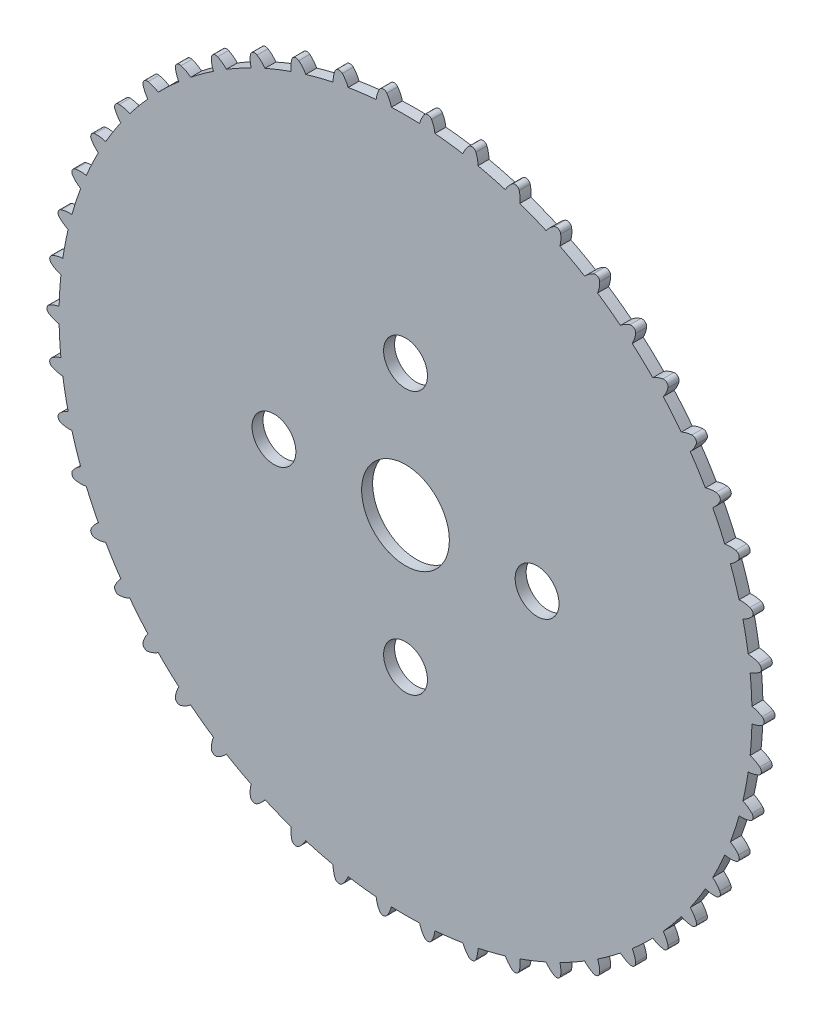
from build123d import *

# Parameters (mm, degrees)
SKETCH1_R           = 4
BOSS_EXTRUDE1_DEPTH = 1
FILLET1_R           = 0.4
FILLET2_R           = 0.4
FILLET3_R           = 0.4
SKETCH2_R           = 2
CUT_EXTRUDE1_DEPTH  = 1


with BuildPart() as part:
    # Sketch1 → Boss-Extrude1 (new body)
    with BuildSketch(Plane.XY):
        with BuildLine():
            ThreePointArc((-31.605983116, -0.694944521), (-31.599169752, -0.69498613), (-31.592356275, -0.695))
            ThreePointArc((-31.592356275, -0.695), (-31.592329775, -0.696203545), (-31.59230323, -0.697407089))
            ThreePointArc((-31.59230323, -0.697407089), (-31.537644618, -1.984180417), (-31.430596768, -3.267657694))
            ThreePointArc((-31.430596768, -3.267657694), (-32.125334488, -3.603800027), (-32.690179408, -4.129730046))
            ThreePointArc((-32.690179408, -4.129730046), (-32.012286653, -4.498665787), (-31.255780197, -4.651473345))
            ThreePointArc((-31.255780197, -4.651473345), (-31.040277123, -5.921249541), (-30.77321102, -7.181189563))
            ThreePointArc((-30.77321102, -7.181189563), (-31.42034072, -7.601755038), (-31.914815159, -8.194331782))
            ThreePointArc((-31.914815159, -8.194331782), (-31.196027882, -8.475395863), (-30.426334839, -8.532183088))
            ThreePointArc((-30.426334839, -8.532183088), (-30.053385915, -9.764937022), (-29.630513351, -10.981469782))
            ThreePointArc((-29.630513351, -10.981469782), (-30.219829409, -11.479825831), (-30.63613521, -12.129704011))
            ThreePointArc((-30.63613521, -12.129704011), (-29.887789115, -12.318463884), (-29.117048005, -12.278335207))
            ThreePointArc((-29.117048005, -12.278335207), (-28.592534858, -13.454625613), (-28.020524786, -14.608565663))
            ThreePointArc((-28.020524786, -14.608565663), (-28.542733336, -15.176852913), (-28.874305107, -15.873783562))
            ThreePointArc((-28.874305107, -15.873783562), (-28.108202059, -15.967262371), (-27.348567931, -15.830850645))
            ThreePointArc((-27.348567931, -15.830850645), (-26.680762446, -16.932126721), (-25.968635806, -18.005275737))
            ThreePointArc((-25.968635806, -18.005275737), (-26.415501307, -18.634531959), (-26.657109965, -19.367524063))
            ThreePointArc((-26.657109965, -19.367524063), (-25.885331866, -19.364247592), (-25.148784602, -19.133704111))
            ThreePointArc((-25.148784602, -19.133704111), (-24.348218472, -20.142598076), (-23.507205927, -21.118031857))
            ThreePointArc((-23.507205927, -21.118031857), (-23.871681043, -21.798333304), (-24.019516274, -22.55582714))
            ThreePointArc((-24.019516274, -22.55582714), (-23.254234527, -22.45584706), (-22.552389918, -22.134807634))
            ThreePointArc((-22.552389918, -22.134807634), (-21.631688547, -23.035408627), (-20.675053368, -23.897743999))
            ThreePointArc((-20.675053368, -23.897743999), (-20.951390109, -24.61836191), (-21.003120462, -25.388411349))
            ThreePointArc((-21.003120462, -25.388411349), (-20.256404017, -25.193304406), (-19.600330572, -24.786832017))
            ThreePointArc((-19.600330572, -24.786832017), (-18.574013972, -25.564937022), (-17.516842866, -26.300574442))
            ThreePointArc((-17.516842866, -26.300574442), (-17.700683236, -27.050144243), (-17.655492895, -27.820605145))
            ThreePointArc((-17.655492895, -27.820605145), (-16.939117916, -27.533448292), (-16.339162305, -27.047953253))
            ThreePointArc((-16.339162305, -27.047953253), (-15.223416102, -27.691291089), (-14.082381289, -28.288629116))
            ThreePointArc((-14.082381289, -28.288629116), (-14.170826016, -29.055329643), (-14.029427657, -29.814051379))
            ThreePointArc((-14.029427657, -29.814051379), (-13.354691806, -29.439373251), (-12.820315687, -28.882512108))
            ThreePointArc((-12.820315687, -28.882512108), (-11.632735865, -29.380936954), (-10.425832146, -29.830555209))
            ThreePointArc((-10.425832146, -29.830555209), (-10.417486404, -30.602295137), (-10.182109965, -31.337312212))
            ThreePointArc((-10.182109965, -31.337312212), (-9.559654229, -30.881021707), (-9.099285033, -30.261576494))
            ThreePointArc((-9.099285033, -30.261576494), (-7.858600434, -30.607227892), (-6.604861402, -30.902035626))
            ThreePointArc((-6.604861402, -30.902035626), (-6.499856808, -31.666644156), (-6.174214316, -32.366364912))
            ThreePointArc((-6.174214316, -32.366364912), (-5.613855194, -31.835658003), (-5.234753218, -31.163397741))
            ThreePointArc((-5.234753218, -31.163397741), (-3.960530181, -31.350824562), (-2.679728048, -31.486172482))
            ThreePointArc((-2.679728048, -31.486172482), (-2.479720587, -32.23159128), (-2.068947618, -32.884980702))
            ThreePointArc((-2.068947618, -32.884980702), (-1.579522308, -32.288226955), (-1.287666218, -31.573753589))
            ThreePointArc((-1.287666218, -31.573753589), (0, -31.6), (1.287666218, -31.573753589))
            ThreePointArc((1.287666218, -31.573753589), (1.579522308, -32.288226955), (2.068947618, -32.884980702))
            ThreePointArc((2.068947618, -32.884980702), (2.479720587, -32.23159128), (2.679728048, -31.486172482))
            ThreePointArc((2.679728048, -31.486172482), (3.960530181, -31.350824562), (5.234753218, -31.163397741))
            ThreePointArc((5.234753218, -31.163397741), (5.613855194, -31.835658003), (6.174214316, -32.366364912))
            ThreePointArc((6.174214316, -32.366364912), (6.499856808, -31.666644156), (6.604861402, -30.902035626))
            ThreePointArc((6.604861402, -30.902035626), (7.858600434, -30.607227892), (9.099285033, -30.261576494))
            ThreePointArc((9.099285033, -30.261576494), (9.559654229, -30.881021707), (10.182109965, -31.337312212))
            ThreePointArc((10.182109965, -31.337312212), (10.417486404, -30.602295137), (10.425832146, -29.830555209))
            ThreePointArc((10.425832146, -29.830555209), (11.632735865, -29.380936954), (12.820315687, -28.882512108))
            ThreePointArc((12.820315687, -28.882512108), (13.354691806, -29.439373251), (14.029427657, -29.814051379))
            ThreePointArc((14.029427657, -29.814051379), (14.170826016, -29.055329643), (14.082381289, -28.288629116))
            ThreePointArc((14.082381289, -28.288629116), (15.223416102, -27.691291089), (16.339162305, -27.047953253))
            ThreePointArc((16.339162305, -27.047953253), (16.939117916, -27.533448292), (17.655492895, -27.820605145))
            ThreePointArc((17.655492895, -27.820605145), (17.700683236, -27.050144243), (17.516842866, -26.300574442))
            ThreePointArc((17.516842866, -26.300574442), (18.574013972, -25.564937022), (19.600330572, -24.786832017))
            ThreePointArc((19.600330572, -24.786832017), (20.256404017, -25.193304406), (21.003120462, -25.388411349))
            ThreePointArc((21.003120462, -25.388411349), (20.951390109, -24.61836191), (20.675053368, -23.897743999))
            ThreePointArc((20.675053368, -23.897743999), (21.631688547, -23.035408627), (22.552389918, -22.134807634))
            ThreePointArc((22.552389918, -22.134807634), (23.254234527, -22.45584706), (24.019516274, -22.55582714))
            ThreePointArc((24.019516274, -22.55582714), (23.871681043, -21.798333304), (23.507205927, -21.118031857))
            ThreePointArc((23.507205927, -21.118031857), (24.348218472, -20.142598076), (25.148784602, -19.133704111))
            ThreePointArc((25.148784602, -19.133704111), (25.885331866, -19.364247592), (26.657109965, -19.367524063))
            ThreePointArc((26.657109965, -19.367524063), (26.415501307, -18.634531959), (25.968635806, -18.005275737))
            ThreePointArc((25.968635806, -18.005275737), (26.680762446, -16.932126721), (27.348567931, -15.830850645))
            ThreePointArc((27.348567931, -15.830850645), (28.108202059, -15.967262371), (28.874305107, -15.873783562))
            ThreePointArc((28.874305107, -15.873783562), (28.542733336, -15.176852913), (28.020524786, -14.608565663))
            ThreePointArc((28.020524786, -14.608565663), (28.592534858, -13.454625613), (29.117048005, -12.278335207))
            ThreePointArc((29.117048005, -12.278335207), (29.887789115, -12.318463884), (30.63613521, -12.129704011))
            ThreePointArc((30.63613521, -12.129704011), (30.219829409, -11.479825831), (29.630513351, -10.981469782))
            ThreePointArc((29.630513351, -10.981469782), (30.053385915, -9.764937022), (30.426334839, -8.532183088))
            ThreePointArc((30.426334839, -8.532183088), (31.196027882, -8.475395863), (31.914815159, -8.194331782))
            ThreePointArc((31.914815159, -8.194331782), (31.42034072, -7.601755038), (30.77321102, -7.181189563))
            ThreePointArc((30.77321102, -7.181189563), (31.040277123, -5.921249541), (31.255780197, -4.651473345))
            ThreePointArc((31.255780197, -4.651473345), (32.012286653, -4.498665787), (32.690179408, -4.129730046))
            ThreePointArc((32.690179408, -4.129730046), (32.125334488, -3.603800027), (31.430596768, -3.267657694))
            ThreePointArc((31.430596768, -3.267657694), (31.537644618, -1.984180417), (31.59230323, -0.697407089))
            ThreePointArc((31.59230323, -0.697407089), (32.323692541, -0.450989063), (32.95, 0))
            ThreePointArc((32.95, 0), (32.323692541, 0.450989063), (31.59230323, 0.697407089))
            ThreePointArc((31.59230323, 0.697407089), (31.537644618, 1.984180417), (31.430596768, 3.267657694))
            ThreePointArc((31.430596768, 3.267657694), (32.125334488, 3.603800027), (32.690179408, 4.129730046))
            ThreePointArc((32.690179408, 4.129730046), (32.012286653, 4.498665787), (31.255780197, 4.651473345))
            ThreePointArc((31.255780197, 4.651473345), (31.040277123, 5.921249541), (30.77321102, 7.181189563))
            ThreePointArc((30.77321102, 7.181189563), (31.42034072, 7.601755038), (31.914815159, 8.194331782))
            ThreePointArc((31.914815159, 8.194331782), (31.196027882, 8.475395863), (30.426334839, 8.532183088))
            ThreePointArc((30.426334839, 8.532183088), (30.053385915, 9.764937022), (29.630513351, 10.981469782))
            ThreePointArc((29.630513351, 10.981469782), (30.219829409, 11.479825831), (30.63613521, 12.129704011))
            ThreePointArc((30.63613521, 12.129704011), (29.887789115, 12.318463884), (29.117048005, 12.278335207))
            ThreePointArc((29.117048005, 12.278335207), (28.592534858, 13.454625613), (28.020524786, 14.608565663))
            ThreePointArc((28.020524786, 14.608565663), (28.542733336, 15.176852913), (28.874305107, 15.873783562))
            ThreePointArc((28.874305107, 15.873783562), (28.108202059, 15.967262371), (27.348567931, 15.830850645))
            ThreePointArc((27.348567931, 15.830850645), (26.680762446, 16.932126721), (25.968635806, 18.005275737))
            ThreePointArc((25.968635806, 18.005275737), (26.415501307, 18.634531959), (26.657109965, 19.367524063))
            ThreePointArc((26.657109965, 19.367524063), (25.885331866, 19.364247592), (25.148784602, 19.133704111))
            ThreePointArc((25.148784602, 19.133704111), (24.348218472, 20.142598076), (23.507205927, 21.118031857))
            ThreePointArc((23.507205927, 21.118031857), (23.871681043, 21.798333304), (24.019516274, 22.55582714))
            ThreePointArc((24.019516274, 22.55582714), (23.254234527, 22.45584706), (22.552389918, 22.134807634))
            ThreePointArc((22.552389918, 22.134807634), (21.631688547, 23.035408627), (20.675053368, 23.897743999))
            ThreePointArc((20.675053368, 23.897743999), (20.951390109, 24.61836191), (21.003120462, 25.388411349))
            ThreePointArc((21.003120462, 25.388411349), (20.256404017, 25.193304406), (19.600330572, 24.786832017))
            ThreePointArc((19.600330572, 24.786832017), (18.574013972, 25.564937022), (17.516842866, 26.300574442))
            ThreePointArc((17.516842866, 26.300574442), (17.700683236, 27.050144243), (17.655492895, 27.820605145))
            ThreePointArc((17.655492895, 27.820605145), (16.939117916, 27.533448292), (16.339162305, 27.047953253))
            ThreePointArc((16.339162305, 27.047953253), (15.223416102, 27.691291089), (14.082381289, 28.288629116))
            ThreePointArc((14.082381289, 28.288629116), (14.170826016, 29.055329643), (14.029427657, 29.814051379))
            ThreePointArc((14.029427657, 29.814051379), (13.354691806, 29.439373251), (12.820315687, 28.882512108))
            ThreePointArc((12.820315687, 28.882512108), (11.632735865, 29.380936954), (10.425832146, 29.830555209))
            ThreePointArc((10.425832146, 29.830555209), (10.417486404, 30.602295137), (10.182109965, 31.337312212))
            ThreePointArc((10.182109965, 31.337312212), (9.559654229, 30.881021707), (9.099285033, 30.261576494))
            ThreePointArc((9.099285033, 30.261576494), (7.858600434, 30.607227892), (6.604861402, 30.902035626))
            ThreePointArc((6.604861402, 30.902035626), (6.499856808, 31.666644156), (6.174214316, 32.366364912))
            ThreePointArc((6.174214316, 32.366364912), (5.613855194, 31.835658003), (5.234753218, 31.163397741))
            ThreePointArc((5.234753218, 31.163397741), (3.960530181, 31.350824562), (2.679728048, 31.486172482))
            ThreePointArc((2.679728048, 31.486172482), (2.479720587, 32.23159128), (2.068947618, 32.884980702))
            ThreePointArc((2.068947618, 32.884980702), (1.579522308, 32.288226955), (1.287666218, 31.573753589))
            ThreePointArc((1.287666218, 31.573753589), (0, 31.6), (-1.287666218, 31.573753589))
            ThreePointArc((-1.287666218, 31.573753589), (-1.579522308, 32.288226955), (-2.068947618, 32.884980702))
            ThreePointArc((-2.068947618, 32.884980702), (-2.479720587, 32.23159128), (-2.679728048, 31.486172482))
            ThreePointArc((-2.679728048, 31.486172482), (-3.960530181, 31.350824562), (-5.234753218, 31.163397741))
            ThreePointArc((-5.234753218, 31.163397741), (-5.613855194, 31.835658003), (-6.174214316, 32.366364912))
            ThreePointArc((-6.174214316, 32.366364912), (-6.499856808, 31.666644156), (-6.604861402, 30.902035626))
            ThreePointArc((-6.604861402, 30.902035626), (-7.858600434, 30.607227892), (-9.099285033, 30.261576494))
            ThreePointArc((-9.099285033, 30.261576494), (-9.559654229, 30.881021707), (-10.182109965, 31.337312212))
            ThreePointArc((-10.182109965, 31.337312212), (-10.417486404, 30.602295137), (-10.425832146, 29.830555209))
            ThreePointArc((-10.425832146, 29.830555209), (-11.632735865, 29.380936954), (-12.820315687, 28.882512108))
            ThreePointArc((-12.820315687, 28.882512108), (-13.354691806, 29.439373251), (-14.029427657, 29.814051379))
            ThreePointArc((-14.029427657, 29.814051379), (-14.170826016, 29.055329643), (-14.082381289, 28.288629116))
            ThreePointArc((-14.082381289, 28.288629116), (-15.223416102, 27.691291089), (-16.339162305, 27.047953253))
            ThreePointArc((-16.339162305, 27.047953253), (-16.939117916, 27.533448292), (-17.655492895, 27.820605145))
            ThreePointArc((-17.655492895, 27.820605145), (-17.700683236, 27.050144243), (-17.516842866, 26.300574442))
            ThreePointArc((-17.516842866, 26.300574442), (-18.574013972, 25.564937022), (-19.600330572, 24.786832017))
            ThreePointArc((-19.600330572, 24.786832017), (-20.256404017, 25.193304406), (-21.003120462, 25.388411349))
            ThreePointArc((-21.003120462, 25.388411349), (-20.951390109, 24.61836191), (-20.675053368, 23.897743999))
            ThreePointArc((-20.675053368, 23.897743999), (-21.631688547, 23.035408627), (-22.552389918, 22.134807634))
            ThreePointArc((-22.552389918, 22.134807634), (-23.254234527, 22.45584706), (-24.019516274, 22.55582714))
            ThreePointArc((-24.019516274, 22.55582714), (-23.871681043, 21.798333304), (-23.507205927, 21.118031857))
            ThreePointArc((-23.507205927, 21.118031857), (-24.348218472, 20.142598076), (-25.148784602, 19.133704111))
            ThreePointArc((-25.148784602, 19.133704111), (-25.885331866, 19.364247592), (-26.657109965, 19.367524063))
            ThreePointArc((-26.657109965, 19.367524063), (-26.415501307, 18.634531959), (-25.968635806, 18.005275737))
            ThreePointArc((-25.968635806, 18.005275737), (-26.680762446, 16.932126721), (-27.348567931, 15.830850645))
            ThreePointArc((-27.348567931, 15.830850645), (-28.108202059, 15.967262371), (-28.874305107, 15.873783562))
            ThreePointArc((-28.874305107, 15.873783562), (-28.542733336, 15.176852913), (-28.020524786, 14.608565663))
            ThreePointArc((-28.020524786, 14.608565663), (-28.592534858, 13.454625613), (-29.117048005, 12.278335207))
            ThreePointArc((-29.117048005, 12.278335207), (-29.887789115, 12.318463884), (-30.63613521, 12.129704011))
            ThreePointArc((-30.63613521, 12.129704011), (-30.219829409, 11.479825831), (-29.630513351, 10.981469782))
            ThreePointArc((-29.630513351, 10.981469782), (-30.053385915, 9.764937022), (-30.426334839, 8.532183088))
            ThreePointArc((-30.426334839, 8.532183088), (-31.196027882, 8.475395863), (-31.914815159, 8.194331782))
            ThreePointArc((-31.914815159, 8.194331782), (-31.42034072, 7.601755038), (-30.77321102, 7.181189563))
            ThreePointArc((-30.77321102, 7.181189563), (-31.040277123, 5.921249541), (-31.255780197, 4.651473345))
            ThreePointArc((-31.255780197, 4.651473345), (-32.012286653, 4.498665787), (-32.690179408, 4.129730046))
            ThreePointArc((-32.690179408, 4.129730046), (-32.125334488, 3.603800027), (-31.430596768, 3.267657694))
            ThreePointArc((-31.430596768, 3.267657694), (-31.537644618, 1.984180417), (-31.59230323, 0.697407089))
            ThreePointArc((-31.59230323, 0.697407089), (-32.074081901, 0.562963084), (-32.521033583, 0.338418939))
            ThreePointArc((-32.521033583, 0.338418939), (-32.707790479, 0), (-32.521033583, -0.338418939))
            ThreePointArc((-32.521033583, -0.338418939), (-32.080561001, -0.560448678), (-31.605983116, -0.694944521))
        make_face()
        Circle(SKETCH1_R, mode=Mode.SUBTRACT)
    extrude(amount=BOSS_EXTRUDE1_DEPTH)

    # Fillet1
    fillet1_edges = [part.edges().sort_by_distance(p)[0] for p in [
        (-30.63613521, 12.129704011, 0.5),
    ]]
    fillet(fillet1_edges, radius=FILLET1_R)

    # Fillet2
    fillet2_edges = [part.edges().sort_by_distance(p)[0] for p in [
        (28.874305107, -15.873783562, 0.5),
        (26.657109965, -19.367524063, 0.5),
        (24.019516274, -22.55582714, 0.5),
        (21.003120462, -25.388411349, 0.5),
        (17.655492895, -27.820605145, 0.5),
        (14.029427657, -29.814051379, 0.5),
        (10.182109965, -31.337312212, 0.5),
        (6.174214316, -32.366364912, 0.5),
        (2.068947618, -32.884980702, 0.5),
        (-2.068947618, -32.884980702, 0.5),
        (-6.174214316, -32.366364912, 0.5),
        (-10.182109965, -31.337312212, 0.5),
        (-14.029427657, -29.814051379, 0.5),
        (-17.655492895, -27.820605145, 0.5),
        (-21.003120462, -25.388411349, 0.5),
        (-24.019516274, -22.55582714, 0.5),
        (-26.657109965, -19.367524063, 0.5),
        (-28.874305107, -15.873783562, 0.5),
        (-31.914815159, -8.194331782, 0.5),
        (-32.690179408, -4.129730046, 0.5),
        (-32.690179408, 4.129730046, 0.5),
        (-31.914815159, 8.194331782, 0.5),
        (17.655492895, 27.820605145, 0.5),
        (21.003120462, 25.388411349, 0.5),
        (24.019516274, 22.55582714, 0.5),
        (26.657109965, 19.367524063, 0.5),
        (28.874305107, 15.873783562, 0.5),
        (30.63613521, 12.129704011, 0.5),
        (31.914815159, 8.194331782, 0.5),
        (32.690179408, 4.129730046, 0.5),
        (32.95, 0, 0.5),
        (32.690179408, -4.129730046, 0.5),
        (31.914815159, -8.194331782, 0.5),
    ]]
    fillet(fillet2_edges, radius=FILLET2_R)

    # Fillet3
    fillet3_edges = [part.edges().sort_by_distance(p)[0] for p in [
        (30.63613521, -12.129704011, 0.5),
        (-30.63613521, -12.129704011, 0.5),
        (-28.874305107, 15.873783562, 0.5),
        (-26.657109965, 19.367524063, 0.5),
        (-24.019516274, 22.55582714, 0.5),
        (-21.003120462, 25.388411349, 0.5),
        (-17.655492895, 27.820605145, 0.5),
        (-14.029427657, 29.814051379, 0.5),
        (-10.182109965, 31.337312212, 0.5),
        (-6.174214316, 32.366364912, 0.5),
        (-2.068947618, 32.884980702, 0.5),
        (2.068947618, 32.884980702, 0.5),
        (6.174214316, 32.366364912, 0.5),
        (10.182109965, 31.337312212, 0.5),
        (14.029427657, 29.814051379, 0.5),
    ]]
    fillet(fillet3_edges, radius=FILLET3_R)

    # Sketch2 → Cut-Extrude1 (cut)
    with BuildSketch(Plane.XY.offset(1)):
        with Locations((12, 0)):
            Circle(SKETCH2_R)
        with Locations((0, -12)):
            Circle(SKETCH2_R)
        with Locations((-12, 0)):
            Circle(SKETCH2_R)
        with Locations((0, 12)):
            Circle(SKETCH2_R)
    extrude(amount=-CUT_EXTRUDE1_DEPTH, mode=Mode.SUBTRACT)


solid = part.part
